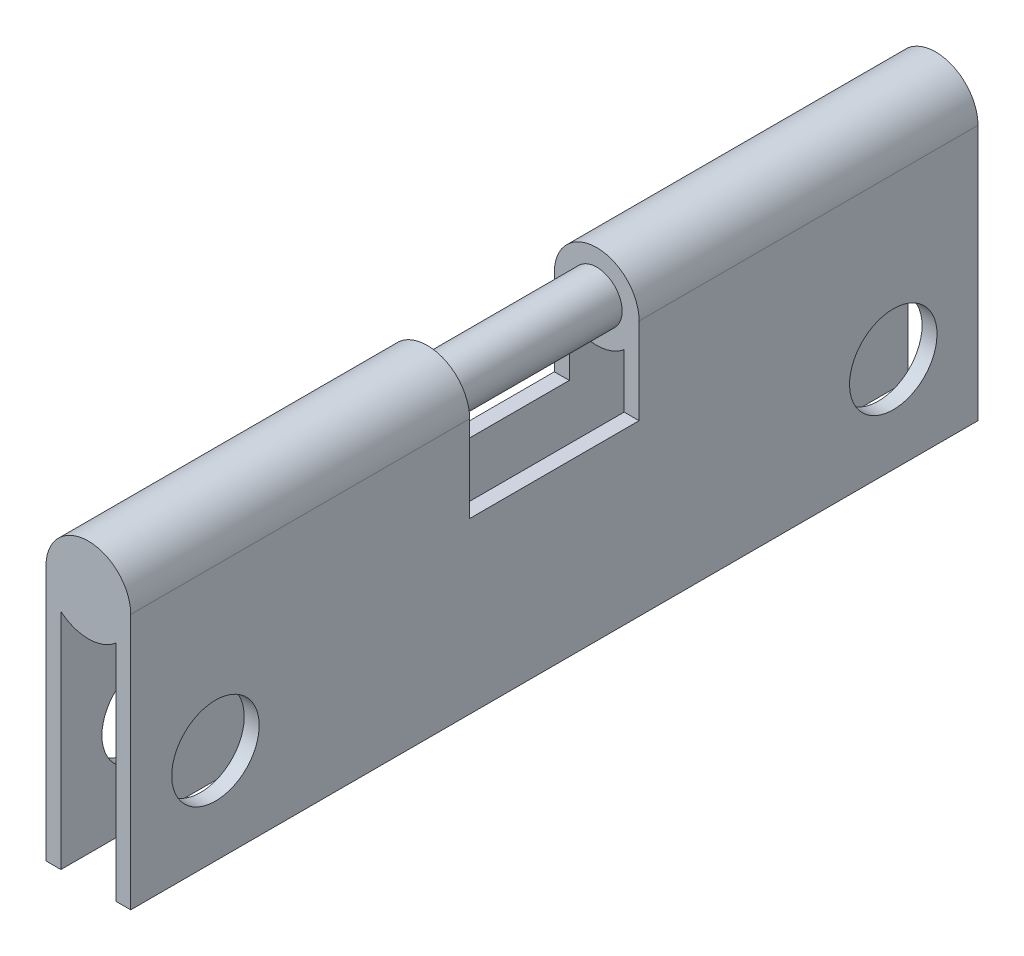
from build123d import *

# Parameters (mm, degrees)
BOSS_EXTRUDE1_DEPTH = 31.75
SKETCH2_R           = 1.6383
SKETCH2_W           = 6.35
SKETCH2_H           = 4.826
CUT_EXTRUDE1_DEPTH  = 4.175
BOSS_EXTRUDE2_REACH = 21.05
SKETCH3_R           = 0.9525


with BuildPart() as part:
    # Sketch1 → Boss-Extrude1 (new body)
    with BuildSketch(Plane.XY):
        with BuildLine():
            Line((1.5875, 0), (1.5875, -9.5885))
            Line((1.5875, -9.5885), (1.0287, -9.5885))
            Line((1.0287, -9.5885), (1.0287, -1.209104032))
            ThreePointArc((1.0287, -1.209104032), (0, -1.5875), (-1.0287, -1.209104032))
            Line((-1.0287, -1.209104032), (-1.0287, -9.5885))
            Line((-1.0287, -9.5885), (-1.5875, -9.5885))
            Line((-1.5875, -9.5885), (-1.5875, 0))
            ThreePointArc((-1.5875, 0), (0, 1.5875), (1.5875, 0))
        make_face()
    extrude(amount=BOSS_EXTRUDE1_DEPTH)

    # Sketch2 → Cut-Extrude1 (cut, through all)
    with BuildSketch(Plane(origin=(1.5875, 0, 0), x_dir=(0, 0, -1), z_dir=(1, 0, 0))):
        with Locations((-28.575, -6.0071)):
            Circle(SKETCH2_R)
        with Locations((-3.175, -6.0071)):
            Circle(SKETCH2_R)
        with Locations((-15.875, -0.8255)):
            Rectangle(SKETCH2_W, SKETCH2_H)
    extrude(amount=-CUT_EXTRUDE1_DEPTH, mode=Mode.SUBTRACT)

    # Sketch3 → Boss-Extrude2 (add, up to next)
    with BuildSketch(Plane.XY.offset(12.7), mode=Mode.PRIVATE) as boss_extrude2_sk1:
        Circle(SKETCH3_R)
    boss_extrude2_tool1 = extrude(boss_extrude2_sk1.sketch, amount=BOSS_EXTRUDE2_REACH, mode=Mode.PRIVATE) - part.part
    add(boss_extrude2_tool1.solids().sort_by_distance((0, 0, 12.7))[0])


solid = part.part
